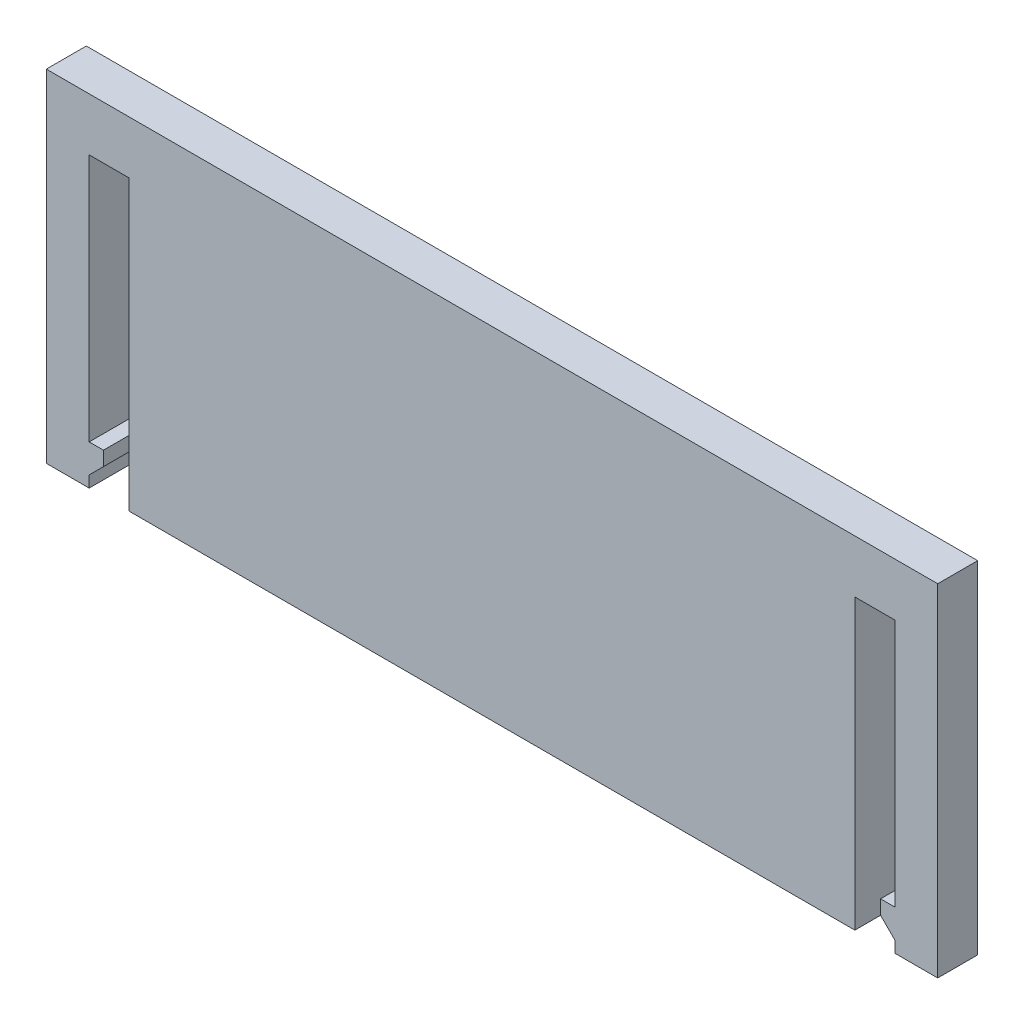
from build123d import *

# Parameters (mm, degrees)
SKETCH1_W                                = 62.4
SKETCH1_H                                = 23.902256307
SKETCH1_W_2                              = 2.8
SKETCH1_H_2                              = 17.402256307
BOSS_EXTRUDE1_DEPTH                      = 2.8
CUT_EXTRUDE1_DEPTH                       = 3.8
SKETCH4_W                                = 44.45
SKETCH4_H                                = 16.51
CUT_EXTRUDE2_DEPTH                       = 1
BOSS_EXTRUDE2_DEPTH                      = 1
MIRROR2_AT_THE_SECOND_PLANE_COPY_1_DEPTH = 1


with BuildPart() as part:
    # Sketch1 → Boss-Extrude1 (new body)
    with BuildSketch(Plane.XY):
        with Locations((-25.4, -14.348584576)):
            Rectangle(SKETCH1_W, SKETCH1_H)
        with Locations((-52.2, -14.798584576)):
            Rectangle(SKETCH1_W_2, SKETCH1_H_2, mode=Mode.SUBTRACT)
        with Locations((1.4, -14.798584576)):
            Rectangle(SKETCH1_W_2, SKETCH1_H_2, mode=Mode.SUBTRACT)
    extrude(amount=BOSS_EXTRUDE1_DEPTH)

    # Sketch2 → Cut-Extrude1 (cut, through all)
    with BuildSketch(Plane.XY.offset(2.8)):
        Polygon((-50.8, -23.499712729), (-52.6, -23.499712729), (-52.6, -24.499712729), (-53.6, -25.499712729), (-53.6, -26.299712729), (-50.8, -26.299712729), align=None)
    cut_extrude1 = extrude(amount=-CUT_EXTRUDE1_DEPTH, mode=Mode.SUBTRACT)

    # Mirror1: Cut-Extrude1 across plane
    add(cut_extrude1.mirror(Plane.ZY.offset(25.4)), mode=Mode.SUBTRACT)

    # Sketch4 → Cut-Extrude2 (cut)
    with BuildSketch(Plane(origin=(0, 0, 0), x_dir=(-1, 0, 0), z_dir=(0, 0, -1))):
        with Locations((25.4, -14.348584576)):
            Rectangle(SKETCH4_W, SKETCH4_H)
    extrude(amount=-CUT_EXTRUDE2_DEPTH, mode=Mode.SUBTRACT)

    # Sketch5 → Boss-Extrude2 (add)
    with BuildSketch(Plane(origin=(0, 0, 1), x_dir=(-1, 0, 0), z_dir=(0, 0, -1))):
        with BuildLine():
            Line((3.175, -6.093584576), (3.825, -6.093584576))
            ThreePointArc((3.825, -6.093584576), (3.346555815, -6.666862483), (3.175, -7.393584576))
            Line((3.175, -7.393584576), (3.175, -6.093584576))
        make_face()
    boss_extrude2 = extrude(amount=BOSS_EXTRUDE2_DEPTH)

    # Mirror2: Boss-Extrude2 across plane
    add(boss_extrude2.mirror(Plane.ZY.offset(25.4)))

    # Mirror2 at the second plane: Boss-Extrude2 across plane
    add(boss_extrude2.mirror(Plane.ZX.offset(-14.348584576)))

    # Mirror2 at the second plane copy 1 sketc → Mirror2 at the second plane copy 1 (add)
    with BuildSketch(Plane(origin=(-50.8, -28.697169151, 1), x_dir=(1, 0, 0), z_dir=(0, 0, -1))):
        with BuildLine():
            Line((3.175, -6.093584576), (3.825, -6.093584576))
            ThreePointArc((3.825, -6.093584576), (3.346555815, -6.666862483), (3.175, -7.393584576))
            Line((3.175, -7.393584576), (3.175, -6.093584576))
        make_face()
    extrude(amount=MIRROR2_AT_THE_SECOND_PLANE_COPY_1_DEPTH)


solid = part.part
